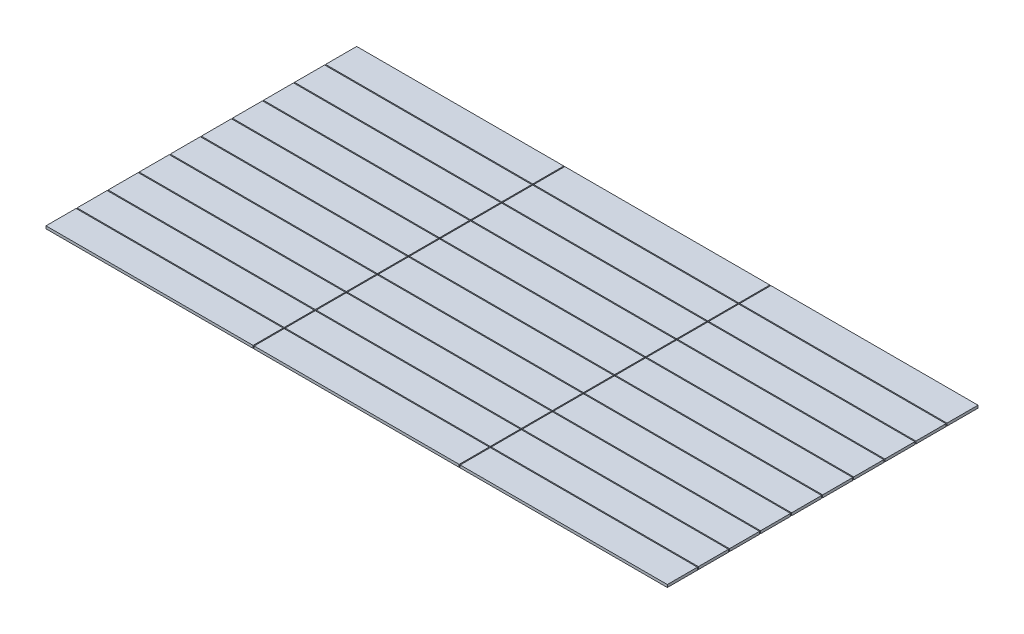
from build123d import *

# Parameters (mm, degrees)
SKETCH_2_W          = 6000
SKETCH_2_H          = 3000
EXTRUDE_1_DEPTH     = 25.4
SKETCH_3_W          = 6000
SKETCH_3_H          = 10
CUT_EXTRUDE_1_DEPTH = 26.4
SKETCH_4_W          = 10
SKETCH_4_H          = 3000
CUT_EXTRUDE_2_DEPTH = 25.4


with BuildPart() as part:
    # 草图2 → 凸台-拉伸1 (new body)
    with BuildSketch(Plane(origin=(0, 0, 0), x_dir=(1, 0, 0), z_dir=(0, 1, 0))):
        with Locations((3000, 1500)):
            Rectangle(SKETCH_2_W, SKETCH_2_H)
    extrude(amount=EXTRUDE_1_DEPTH)

    # 草图3 → 切除-拉伸1 (cut, through all)
    with BuildSketch(Plane(origin=(0, 25.4, 0), x_dir=(1, 0, 0), z_dir=(0, 1, 0))):
        with Locations((3000, 2695)):
            Rectangle(SKETCH_3_W, SKETCH_3_H)
        with Locations((3000, 2395)):
            Rectangle(SKETCH_3_W, SKETCH_3_H)
        with Locations((3000, 2095)):
            Rectangle(SKETCH_3_W, SKETCH_3_H)
        with Locations((3000, 1795)):
            Rectangle(SKETCH_3_W, SKETCH_3_H)
        with Locations((3000, 1495)):
            Rectangle(SKETCH_3_W, SKETCH_3_H)
        with Locations((3000, 895)):
            Rectangle(SKETCH_3_W, SKETCH_3_H)
        with Locations((3000, 1195)):
            Rectangle(SKETCH_3_W, SKETCH_3_H)
        with Locations((3000, 595)):
            Rectangle(SKETCH_3_W, SKETCH_3_H)
        with Locations((3000, 295)):
            Rectangle(SKETCH_3_W, SKETCH_3_H)
    extrude(amount=-CUT_EXTRUDE_1_DEPTH, mode=Mode.SUBTRACT)

    # 草图4 → 切除-拉伸2 (cut)
    with BuildSketch(Plane(origin=(0, 25.4, 0), x_dir=(1, 0, 0), z_dir=(0, 1, 0))):
        with Locations((2005, 1500)):
            Rectangle(SKETCH_4_W, SKETCH_4_H)
        with Locations((3995, 1500)):
            Rectangle(SKETCH_4_W, SKETCH_4_H)
    extrude(amount=-CUT_EXTRUDE_2_DEPTH, mode=Mode.SUBTRACT)


solid = part.part
